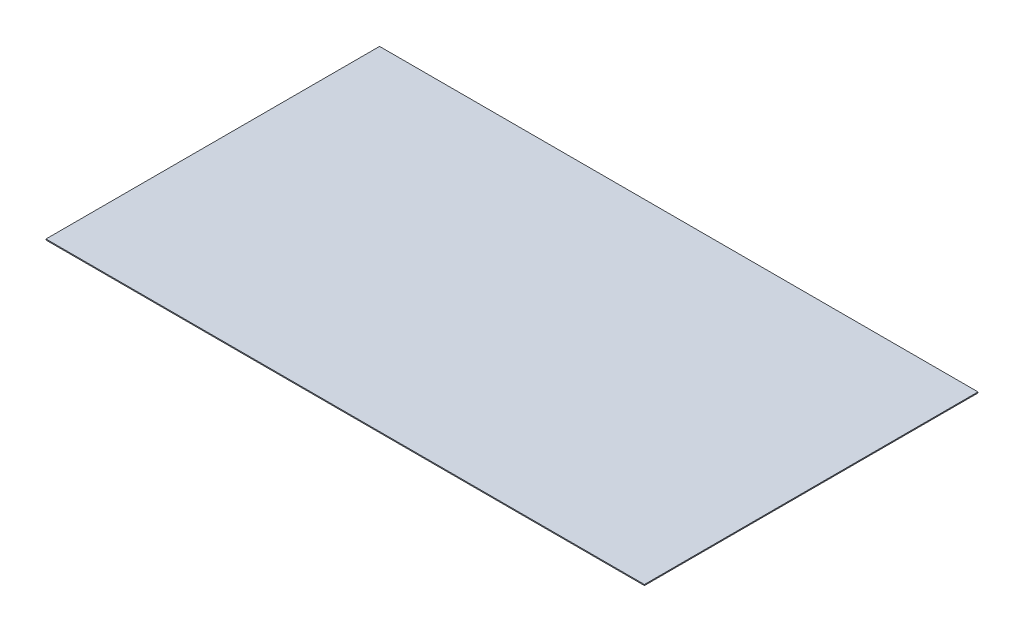
from build123d import *

# Parameters (mm, degrees)
ESQUISSE1_W      = 610
ESQUISSE1_H      = 340
EXTRUSION1_DEPTH = 1


with BuildPart() as part:
    # Esquisse1 → Extrusion1 (new body)
    with BuildSketch(Plane(origin=(0, 0, 0), x_dir=(1, 0, 0), z_dir=(0, 1, 0))):
        with Locations((305, 170)):
            Rectangle(ESQUISSE1_W, ESQUISSE1_H)
    extrude(amount=EXTRUSION1_DEPTH)


solid = part.part
